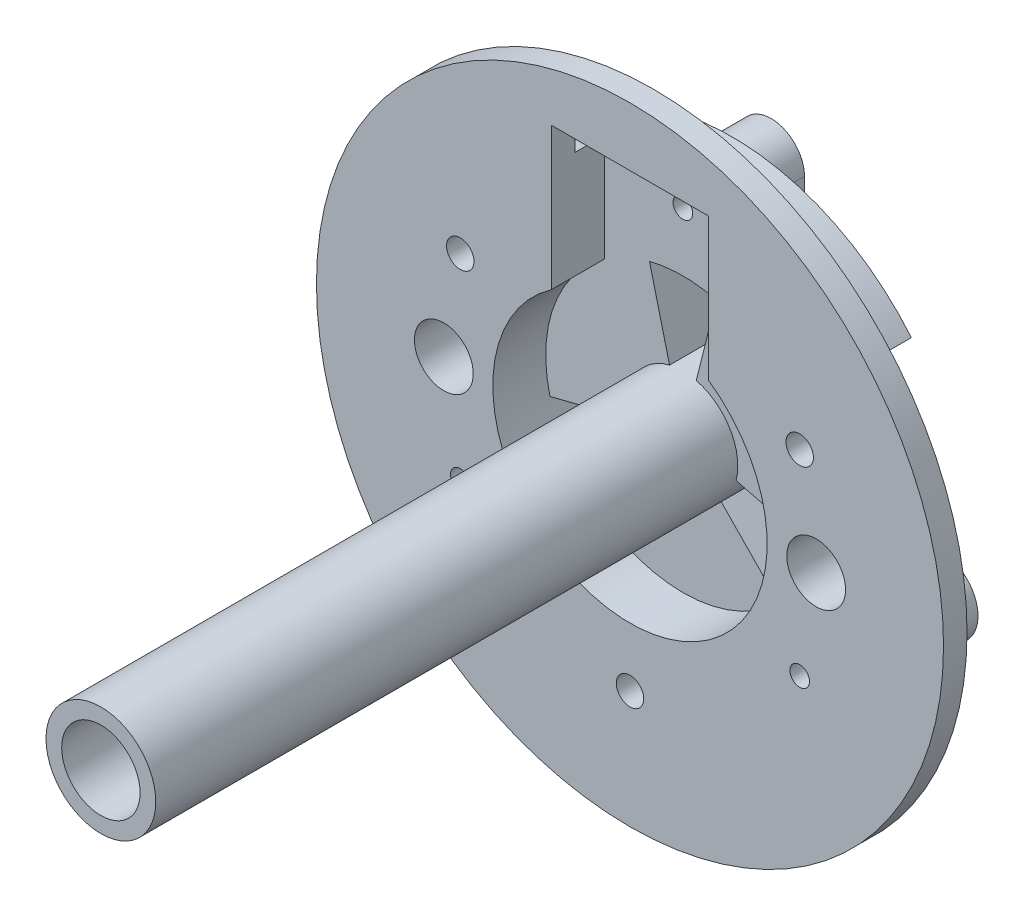
from build123d import *
from build123d.topology import SkipClean

# Parameters (mm, degrees)
SKETCH_1_R                = 16
EXTRUDE_1_DEPTH           = 1.2
SKETCH_2_R                = 7
CUT_EXTRUDE_1_DEPTH       = 1.2
SKETCH_3_R                = 0.7
CUT_EXTRUDE_2_DEPTH       = 1.2
SKETCH_4_R                = 0.9
EXTRUDE_2_DEPTH           = 6
SKETCH_5_R                = 7
CUT_EXTRUDE_3_DEPTH       = 11
SKETCH_6_R                = 11.9
SKETCH_6_R_2              = 7
EXTRUDE_3_DEPTH           = 4
SKETCH_7_R                = 0.7
CUT_EXTRUDE_4_DEPTH       = 13
SKETCH_8_R                = 2.8
EXTRUDE_4_DEPTH           = 33
EXTRUDE_START             = -2.5
EXTRUDE_5_DEPTH           = 2.5
SKETCH_10_R               = 1.5
CUT_EXTRUDE_5_DEPTH       = 33.5
SKETCH_12_W               = 13.813743992
SKETCH_12_H               = 10.461201588
CUT_EXTRUDE_6_DEPTH       = 16.75
SKETCH_13_R               = 2
CUT_EXTRUDE_7_DEPTH       = 1.5
SKETCH_14_R               = 2.8
SKETCH_14_R_2             = 2
EXTRUDE_6_DEPTH           = 8.25
CUT_EXTRUDE_9_DEPTH       = 1.5
EXTRUDE_START_2           = -32.2
SKETCH_17_R               = 1.5
SKETCH_17_R_2             = 1.48
EXTRUDE_7_DEPTH           = 32.2
CUT_EXTRUDE_10_DEPTH      = 2.7
SKETCH_19_R               = 0.5
CUT_EXTRUDE_11_DEPTH      = 10
CUT_EXTRUDE_START         = -45
SKETCH_20_R               = 2
CUT_EXTRUDE_12_DEPTH      = 45
SKETCH_22_R               = 1.5
CUT_EXTRUDE_14_DEPTH      = 10
CUT_EXTRUDE_15_DEPTH      = 6.5
CUT_EXTRUDE_15_DEPTH_BACK = 1.5


with BuildPart() as part:
    # 草图1 → 凸台-拉伸1 (new body)
    with BuildSketch(Plane.XY):
        Circle(SKETCH_1_R)
    extrude(amount=EXTRUDE_1_DEPTH)

    # 草图2 → 切除-拉伸1 (cut)
    with BuildSketch(Plane.XY.offset(1.2)):
        Circle(SKETCH_2_R)
    extrude(amount=-CUT_EXTRUDE_1_DEPTH, mode=Mode.SUBTRACT)

    # 草图3 → 切除-拉伸2 (cut)
    with BuildSketch(Plane.XY.offset(1.2)):
        with Locations((8.660254038, 5)):
            Circle(SKETCH_3_R)
        with Locations((0, -10)):
            Circle(SKETCH_3_R)
        with Locations((-8.660254038, 5)):
            Circle(SKETCH_3_R)
    extrude(amount=-CUT_EXTRUDE_2_DEPTH, mode=Mode.SUBTRACT)

    # 草图4 → 凸台-拉伸2 (add)
    # profile 1 of 3: a face of its own
    with BuildSketch(Plane(origin=(0, 0, 0), x_dir=(-1, 0, 0), z_dir=(0, 0, -1))):
        with BuildLine():
            Line((1.703894623, 10), (1.703894623, 5.395195442))
            Line((1.703894623, 5.395195442), (-1.703894623, 5.395195442))
            Line((-1.703894623, 5.395195442), (-1.703894623, 10))
            ThreePointArc((-1.703894623, 10), (0, 11.703894623), (1.703894623, 10))
        make_face()
        with Locations((0, 10)):
            Circle(SKETCH_4_R, mode=Mode.SUBTRACT)
    # profile 2 of 3: a face of its own
    with BuildSketch(Plane(origin=(0, 0, 0), x_dir=(-1, 0, 0), z_dir=(0, 0, -1))):
        with BuildLine():
            Line((-5.537946003, -1.003403593), (-3.637946003, -4.294300127))
            Line((-3.637946003, -4.294300127), (-7.710254038, -6.645448267))
            ThreePointArc((-7.710254038, -6.645448267), (-10.305702305, -5.95), (-9.610254038, -3.354551733))
            Line((-9.610254038, -3.354551733), (-5.537946003, -1.003403593))
        make_face()
        with Locations((-8.660254038, -5)):
            Circle(SKETCH_4_R, mode=Mode.SUBTRACT)
    # profile 3 of 3: a face of its own
    with BuildSketch(Plane(origin=(0, 0, 0), x_dir=(-1, 0, 0), z_dir=(0, 0, -1))):
        with BuildLine():
            Line((3.637946003, -4.294300127), (5.537946003, -1.003403593))
            Line((5.537946003, -1.003403593), (9.610254038, -3.354551733))
            ThreePointArc((9.610254038, -3.354551733), (10.305702305, -5.95), (7.710254038, -6.645448267))
            Line((7.710254038, -6.645448267), (3.637946003, -4.294300127))
        make_face()
        with Locations((8.660254038, -5)):
            Circle(SKETCH_4_R, mode=Mode.SUBTRACT)
    extrude(amount=EXTRUDE_2_DEPTH)

    # 草图5 → 切除-拉伸3 (cut)
    with BuildSketch(Plane.XY.offset(1.2)):
        Circle(SKETCH_5_R)
    extrude(amount=-CUT_EXTRUDE_3_DEPTH, mode=Mode.SUBTRACT)

    # 草图6 → 凸台-拉伸3 (add)
    with SkipClean():  # the faces are left unmerged after this step: merging them gives an invalid solid
        with BuildSketch(Plane(origin=(0, 0, 0), x_dir=(-1, 0, 0), z_dir=(0, 0, -1))):
            Circle(SKETCH_6_R)
            Circle(SKETCH_6_R_2, mode=Mode.SUBTRACT)
        extrude(amount=EXTRUDE_3_DEPTH)

    # 草图7 → 切除-拉伸4 (cut)
    with SkipClean():  # the faces are left unmerged after this step: merging them gives an invalid solid
        with BuildSketch(Plane.XY.offset(1.2)):
            with Locations((-8.660254038, 5)):
                Circle(SKETCH_7_R)
            with Locations((8.660254038, 5)):
                Circle(SKETCH_7_R)
            with Locations((0, -10)):
                Circle(SKETCH_7_R)
        extrude(amount=-CUT_EXTRUDE_4_DEPTH, mode=Mode.SUBTRACT)



with BuildPart() as body_2:
    # 草图8 → 凸台-拉伸4 (new body)
    with BuildSketch(Plane(origin=(0, 0, -4), x_dir=(-1, 0, 0), z_dir=(0, 0, -1))):
        Circle(SKETCH_8_R)
    extrude(amount=-EXTRUDE_4_DEPTH)


with BuildPart() as part_1:
    with SkipClean():  # the faces are left unmerged after this step: merging them gives an invalid solid
        add(part.part)

        add(body_2.part)  # 凸台-拉伸5 merges body 2
        # 草图9 → 凸台-拉伸5 (add)
        with BuildSketch(Plane(origin=(0, 0, -4), x_dir=(-1, 0, 0), z_dir=(0, 0, -1)).offset(EXTRUDE_START)):
            with BuildLine():
                Line((-1.570048426, -1.611659996), (-4.884595102, -5.01405332))
                ThreePointArc((-4.884595102, -5.01405332), (0, -7), (4.884595102, -5.01405332))
                Line((4.884595102, -5.01405332), (1.570048426, -1.611659996))
                ThreePointArc((1.570048426, -1.611659996), (0, -2.25), (-1.570048426, -1.611659996))
            make_face()
            with BuildLine():
                Line((-2.180762711, -0.553871824), (-6.784595102, -1.723156785))
                ThreePointArc((-6.784595102, -1.723156785), (-6.010804278, 3.587510548), (-1.703894623, 6.789458234))
                Line((-1.703894623, 6.789458234), (-0.547680415, 2.182325861))
                ThreePointArc((-0.547680415, 2.182325861), (-1.932044232, 1.15312839), (-2.180762711, -0.553871824))
            make_face()
            with BuildLine():
                Line((0.547680415, 2.182325861), (1.703894623, 6.789458234))
                ThreePointArc((1.703894623, 6.789458234), (6.010804278, 3.587510548), (6.784595102, -1.723156785))
                Line((6.784595102, -1.723156785), (2.180762711, -0.553871824))
                ThreePointArc((2.180762711, -0.553871824), (1.932044232, 1.15312839), (0.547680415, 2.182325861))
            make_face()
        extrude(amount=EXTRUDE_5_DEPTH)

    # 草图10 → 切除-拉伸5 (cut)
    with SkipClean():  # the faces are left unmerged after this step: merging them gives an invalid solid
        with BuildSketch(Plane(origin=(0, 0, -4), x_dir=(-1, 0, 0), z_dir=(0, 0, -1))):
            Circle(SKETCH_10_R)
        extrude(amount=-CUT_EXTRUDE_5_DEPTH, mode=Mode.SUBTRACT)

    # 草图12 → 切除-拉伸6 (cut, symmetric)
    with SkipClean():  # the faces are left unmerged after this step: merging them gives an invalid solid
        with BuildSketch(Plane(origin=(0, 0, 0), x_dir=(0, 0, -1), z_dir=(1, 0, 0))):
            with Locations((-26.856871996, 0.140862114)):
                Rectangle(SKETCH_12_W, SKETCH_12_H)
        extrude(amount=CUT_EXTRUDE_6_DEPTH, both=True, mode=Mode.SUBTRACT)

    # 草图13 → 切除-拉伸7 (cut)
    with SkipClean():  # the faces are left unmerged after this step: merging them gives an invalid solid
        with BuildSketch(Plane(origin=(0, 0, -4), x_dir=(-1, 0, 0), z_dir=(0, 0, -1))):
            with Locations((0, -10)):
                Circle(SKETCH_13_R)
            with Locations((8.660254038, 5)):
                Circle(SKETCH_13_R)
            with Locations((-8.660254038, 5)):
                Circle(SKETCH_13_R)
        extrude(amount=-CUT_EXTRUDE_7_DEPTH, mode=Mode.SUBTRACT)

    # 草图14 → 凸台-拉伸6 (add)
    with SkipClean():  # the faces are left unmerged after this step: merging them gives an invalid solid
        with BuildSketch(Plane.XY.offset(19.95)):
            Circle(SKETCH_14_R)
            Circle(SKETCH_14_R_2, mode=Mode.SUBTRACT)
        extrude(amount=EXTRUDE_6_DEPTH)

    # 草图16 → 切除-拉伸9 (cut)
    with SkipClean():  # the faces are left unmerged after this step: merging them gives an invalid solid
        with BuildSketch(Plane(origin=(0, 0, -4), x_dir=(-1, 0, 0), z_dir=(0, 0, -1))):
            Polygon((0, -10), (-2, -10), (-2, -14.130337011), (2, -14.130337011), (2, -10), align=None)
            Polygon((-9.660254038, 3.267949192), (-8.660254038, 5), (-7.660254038, 6.732050808), (-11.237230815, 8.797219313), (-13.237230815, 5.333117698), align=None)
            Polygon((7.660254038, 6.732050808), (8.660254038, 5), (9.660254038, 3.267949192), (13.237230815, 5.333117698), (11.237230815, 8.797219313), align=None)
        extrude(amount=-CUT_EXTRUDE_9_DEPTH, mode=Mode.SUBTRACT)

    # 草图17 → 凸台-拉伸7 (add)
    with SkipClean():  # the faces are left unmerged after this step: merging them gives an invalid solid
        with BuildSketch(Plane.XY.offset(28.2).offset(EXTRUDE_START_2)):
            Circle(SKETCH_17_R)
            Circle(SKETCH_17_R_2, mode=Mode.SUBTRACT)
        extrude(amount=EXTRUDE_7_DEPTH)

    # 草图18 → 切除-拉伸10 (cut)
    with SkipClean():  # the faces are left unmerged after this step: merging them gives an invalid solid
        with BuildSketch(Plane.XY.offset(1.2)):
            Polygon((0, 13), (-4, 13), (-4, 4.729732775), (4, 4.729732775), (4, 13), align=None)
        extrude(amount=-CUT_EXTRUDE_10_DEPTH, mode=Mode.SUBTRACT)

    # 草图19 → 切除-拉伸11 (cut)
    with SkipClean():  # the faces are left unmerged after this step: merging them gives an invalid solid
        with BuildSketch(Plane(origin=(0, 0, -6), x_dir=(-1, 0, 0), z_dir=(0, 0, -1))):
            with Locations((-8.660254038, -5)):
                Circle(SKETCH_19_R)
            with Locations((0, 10)):
                Circle(SKETCH_19_R)
            with Locations((8.660254038, -5)):
                Circle(SKETCH_19_R)
        extrude(amount=-CUT_EXTRUDE_11_DEPTH, mode=Mode.SUBTRACT)

    # 草图20 → 切除-拉伸12 (cut)
    with SkipClean():  # the faces are left unmerged after this step: merging them gives an invalid solid
        with BuildSketch(Plane.XY.offset(28.2).offset(CUT_EXTRUDE_START)):
            Circle(SKETCH_20_R)
        extrude(amount=CUT_EXTRUDE_12_DEPTH, mode=Mode.SUBTRACT)

    # 草图22 → 切除-拉伸14 (cut)
    with SkipClean():  # the faces are left unmerged after this step: merging them gives an invalid solid
        with BuildSketch(Plane(origin=(0, 0, -4), x_dir=(-1, 0, 0), z_dir=(0, 0, -1))):
            with Locations((-9.499973669, -0.022366959)):
                Circle(SKETCH_22_R)
            with Locations((9.499973669, 0.022366959)):
                Circle(SKETCH_22_R)
        extrude(amount=-CUT_EXTRUDE_14_DEPTH, mode=Mode.SUBTRACT)

    # 草图23 → 切除-拉伸15 (cut, two sides: drawn at the far end of the back side and taken through both)
    with SkipClean():  # the faces are left unmerged after this step: merging them gives an invalid solid
        with BuildSketch(Plane(origin=(0, 0, -4), x_dir=(-1, 0, 0), z_dir=(0, 0, -1)).offset(-CUT_EXTRUDE_15_DEPTH_BACK)):
            with BuildLine():
                add(Edge.make_bspline(
                    [(-7.121212498, 6.277243571), (-6.821609211, 5.881155327), (-6.570774942, 3.730975944), (-6.405853792, 1.260148547), (-5.621216873, -3.66441676), (-13.574102734, -3.757184545), (-12.859596139, 1.806575186), (-12.738209854, 6.264236784), (-7.880948368, 7.281646593), (-7.121212498, 6.277243571)],
                    knots=[0, 0, 0, 0, 0.061157202, 0.210557013, 0.307572563, 0.535591502, 0.660347949, 0.844917188, 1, 1, 1, 1], degree=3))
            make_face()
            with BuildLine():
                add(Edge.make_bspline(
                    [(7.392336591, 5.919350396), (7.056588189, 5.61470833), (6.232527974, 3.985065654), (6.733830257, 1.478017639), (5.321853456, -3.155651751), (13.41155017, -3.747160638), (12.657263888, 1.814301992), (12.465041058, 6.407526768), (8.307512695, 6.749737492), (7.392336591, 5.919350396)],
                    knots=[0, 0, 0, 0, 0.052678072, 0.196881369, 0.29762537, 0.532302493, 0.663021186, 0.856411191, 1, 1, 1, 1], degree=3))
            make_face()
        extrude(amount=CUT_EXTRUDE_15_DEPTH + CUT_EXTRUDE_15_DEPTH_BACK, mode=Mode.SUBTRACT)


solid = part_1.part
